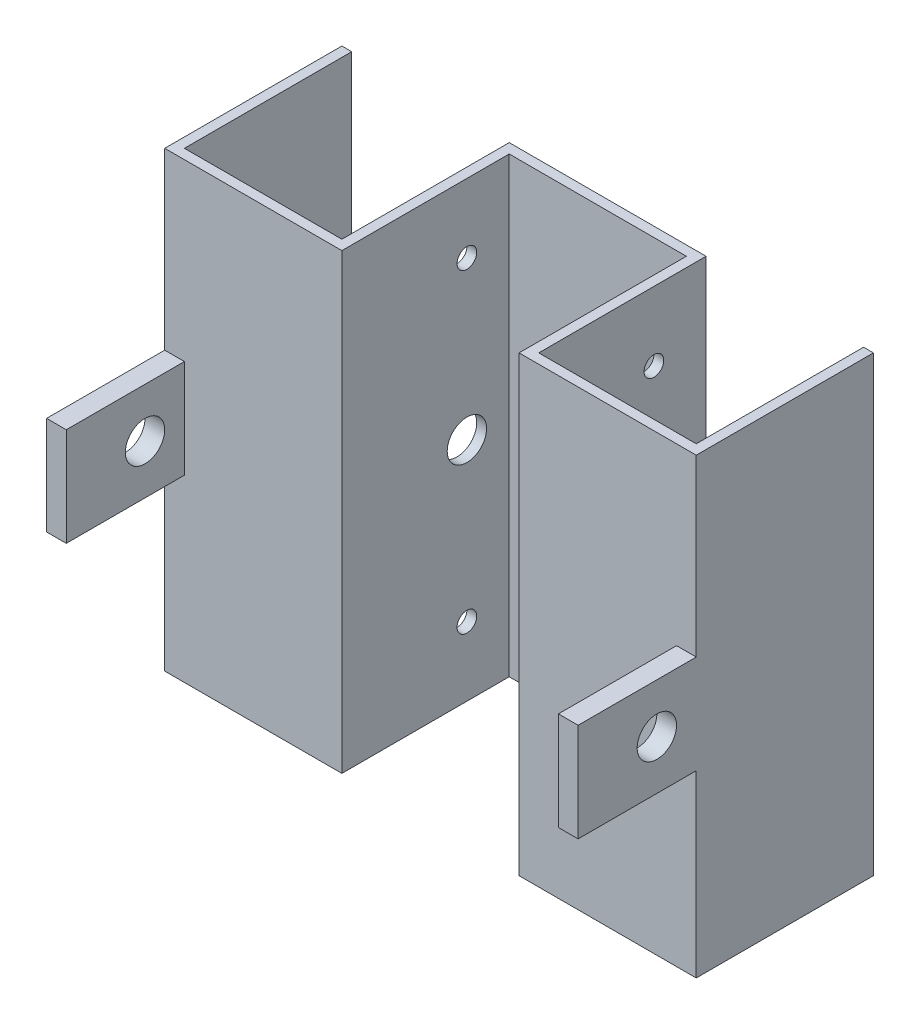
from build123d import *

# Parameters (mm, degrees)
ESQUISSE1_W             = 50
ESQUISSE1_H             = 250
BOSS_EXTRU_1_DEPTH      = 5
ESQUISSE2_W             = 5
ESQUISSE2_H             = 250
BOSS_EXTRU_2_DEPTH      = 80
ESQUISSE3_W             = 85
ESQUISSE3_H             = 250
BOSS_EXTRU_3_DEPTH      = 5
ESQUISSE4_W             = 90
ESQUISSE4_H             = 250
BOSS_EXTRU_4_DEPTH      = 5
ESQUISSE5_R             = 10
ENL_V_MAT_EXTRU_1_DEPTH = 5
ESQUISSE6_R             = 5
ENL_V_MAT_EXTRU_2_DEPTH = 5
ESQUISSE8_R             = 20
ESQUISSE8_R_2           = 10
BOSS_EXTRU_5_DEPTH      = 10
ESQUISSE9_W             = 60
ESQUISSE9_H             = 50
ESQUISSE9_R             = 10
BOSS_EXTRU_6_DEPTH      = 10
ESQUISSE11_W            = 90
ESQUISSE11_H            = 10
ENL_V_MAT_EXTRU_6_DEPTH = 271


with BuildPart() as part:
    # Esquisse1 → Boss.-Extru.1 (new body)
    with BuildSketch(Plane.XY):
        with Locations((-25, 125)):
            Rectangle(ESQUISSE1_W, ESQUISSE1_H)
    boss_extru_1 = extrude(amount=BOSS_EXTRU_1_DEPTH)

    # Esquisse2 → Boss.-Extru.2 (add)
    with BuildSketch(Plane.XY.offset(5)):
        with Locations((-47.5, 125)):
            Rectangle(ESQUISSE2_W, ESQUISSE2_H)
    boss_extru_2 = extrude(amount=BOSS_EXTRU_2_DEPTH)

    # Esquisse3 → Boss.-Extru.3 (add)
    with BuildSketch(Plane.XY.offset(85)):
        with Locations((-87.5, 125)):
            Rectangle(ESQUISSE3_W, ESQUISSE3_H)
    boss_extru_3 = extrude(amount=BOSS_EXTRU_3_DEPTH)

    # Esquisse4 → Boss.-Extru.4 (add)
    with BuildSketch(Plane.ZY.offset(130)):
        with Locations((45, 125)):
            Rectangle(ESQUISSE4_W, ESQUISSE4_H)
    boss_extru_4 = extrude(amount=BOSS_EXTRU_4_DEPTH)

    # Esquisse5 → Enlèv. mat.-Extru.1 (cut)
    with BuildSketch(Plane.ZY.offset(50)):
        with Locations((26.5, 125)):
            Circle(ESQUISSE5_R)
    enl_v_mat_extru_1 = extrude(amount=-ENL_V_MAT_EXTRU_1_DEPTH, mode=Mode.SUBTRACT)

    # Esquisse6 → Enlèv. mat.-Extru.2 (cut)
    with BuildSketch(Plane.ZY.offset(50)):
        with Locations((26.5, 205)):
            Circle(ESQUISSE6_R)
        with Locations((26.5, 45)):
            Circle(ESQUISSE6_R)
    enl_v_mat_extru_2 = extrude(amount=-ENL_V_MAT_EXTRU_2_DEPTH, mode=Mode.SUBTRACT)

    # Symétrie2: Boss.-Extru.1, Boss.-Extru.2, Boss.-Extru.3, Boss.-Extru.4, Enlèv. mat.-Extru.1, Enlèv. mat.-Extru.2 across plane
    add(boss_extru_1.mirror(Plane(origin=(0, 0, 5), x_dir=(0, 0, 1), z_dir=(-1, 0, 0))))
    add(boss_extru_2.mirror(Plane(origin=(0, 0, 5), x_dir=(0, 0, 1), z_dir=(-1, 0, 0))))
    add(boss_extru_3.mirror(Plane(origin=(0, 0, 5), x_dir=(0, 0, 1), z_dir=(-1, 0, 0))))
    add(boss_extru_4.mirror(Plane(origin=(0, 0, 5), x_dir=(0, 0, 1), z_dir=(-1, 0, 0))))
    add(enl_v_mat_extru_1.mirror(Plane(origin=(0, 0, 5), x_dir=(0, 0, 1), z_dir=(-1, 0, 0))), mode=Mode.SUBTRACT)
    add(enl_v_mat_extru_2.mirror(Plane(origin=(0, 0, 5), x_dir=(0, 0, 1), z_dir=(-1, 0, 0))), mode=Mode.SUBTRACT)

    # Esquisse8 → Boss.-Extru.5 (add)
    with BuildSketch(Plane(origin=(135, 0, 0), x_dir=(0, 0, -1), z_dir=(1, 0, 0))):
        Polygon((-90, 101.191980235), (-90, 125), (-90, 126.191980235), (-90, 151.191980235), (-150, 151.191980235), (-150, 125), (-150, 101.191980235), align=None)
        with Locations((-110, 126.191980235)):
            Circle(ESQUISSE8_R, mode=Mode.SUBTRACT)
        with Locations((-110, 126.191980235)):
            Circle(ESQUISSE8_R)
        with Locations((-110, 126.191980235)):
            Circle(ESQUISSE8_R_2, mode=Mode.SUBTRACT)
    extrude(amount=-BOSS_EXTRU_5_DEPTH)

    # Esquisse9 → Boss.-Extru.6 (add)
    with BuildSketch(Plane.ZY.offset(135)):
        with Locations((120, 126.191980235)):
            Rectangle(ESQUISSE9_W, ESQUISSE9_H)
        with Locations((110, 126.191980235)):
            Circle(ESQUISSE9_R, mode=Mode.SUBTRACT)
    extrude(amount=-BOSS_EXTRU_6_DEPTH)

    # Esquisse11 → Enlèv. mat.-Extru.6 (cut, through all)
    with BuildSketch(Plane(origin=(135, 0, 0), x_dir=(0, 0, -1), z_dir=(1, 0, 0))):
        with Locations((-45, 5)):
            Rectangle(ESQUISSE11_W, ESQUISSE11_H)
        with Locations((-45, 245)):
            Rectangle(ESQUISSE11_W, ESQUISSE11_H)
    extrude(amount=-ENL_V_MAT_EXTRU_6_DEPTH, mode=Mode.SUBTRACT)


solid = part.part
